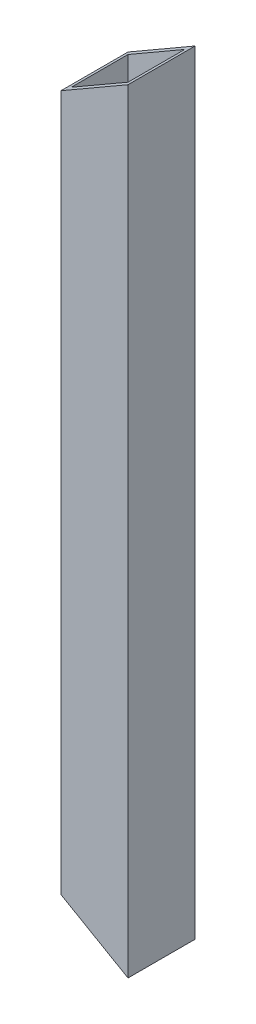
from build123d import *

# Parameters (mm, degrees)
SKETCH1_W               = 13
SKETCH1_H               = 13
SKETCH1_W_2             = 11
SKETCH1_H_2             = 11
BOSS_EXTRUDE1_DEPTH     = 150
CUT_EXTRUDE1_DEPTH      = 1
CUT_EXTRUDE1_DEPTH_BACK = 14
SKETCH3_OUTSIDE_W       = 45.224
SKETCH3_OUTSIDE_H       = 182.224
CUT_EXTRUDE2_DEPTH      = 1
CUT_EXTRUDE2_DEPTH_BACK = 14


with BuildPart() as part:
    # Sketch1 → Boss-Extrude1 (new body)
    with BuildSketch(Plane(origin=(0, 0, 0), x_dir=(1, 0, 0), z_dir=(0, 1, 0))):
        Rectangle(SKETCH1_W, SKETCH1_H)
        Rectangle(SKETCH1_W_2, SKETCH1_H_2, mode=Mode.SUBTRACT)
    extrude(amount=BOSS_EXTRUDE1_DEPTH)

    # Sketch2 → Cut-Extrude1 (cut, two sides)
    with BuildSketch(Plane.XY.offset(6.5)) as cut_extrude1_sk:
        Polygon((275.941771788, 305.562279473), (6.5, 150), (-6.5, 142.494446501), (-275.941771788, -13.067832972), (-587.066330733, 525.815710604), (-35.182787157, 844.445823048), align=None)
    extrude(amount=CUT_EXTRUDE1_DEPTH, mode=Mode.SUBTRACT)
    extrude(cut_extrude1_sk.sketch, amount=-CUT_EXTRUDE1_DEPTH_BACK, mode=Mode.SUBTRACT)

    # Sketch3 outside → Cut-Extrude2 (cut, two sides)
    with BuildSketch(Plane.XY.offset(6.5)) as cut_extrude2_sk:
        with Locations((0, 75)):
            Rectangle(SKETCH3_OUTSIDE_W, SKETCH3_OUTSIDE_H)
        Polygon((6.5, 0), (-6.5, 7.505553499), (-6.5, 142.494446501), (6.5, 150), align=None, mode=Mode.SUBTRACT)
    extrude(amount=CUT_EXTRUDE2_DEPTH, mode=Mode.SUBTRACT)
    extrude(cut_extrude2_sk.sketch, amount=-CUT_EXTRUDE2_DEPTH_BACK, mode=Mode.SUBTRACT)


solid = part.part
